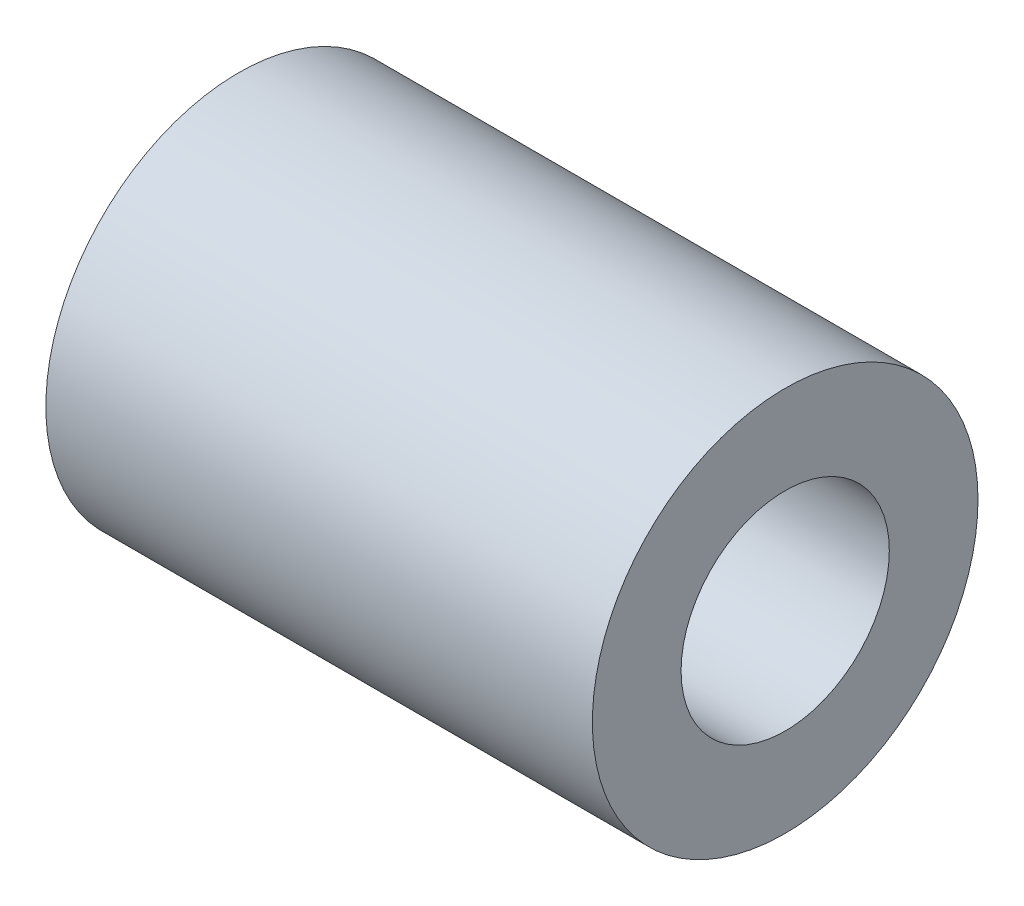
from build123d import *

# Parameters (mm, degrees)
ESQUISSE1_R        = 6.35
ESQUISSE1_R_2      = 3.429
BOSS_EXTRU_1_DEPTH = 18


with BuildPart() as part:
    # Esquisse1 → Boss.-Extru.1 (new body)
    with BuildSketch(Plane(origin=(0, 0, 0), x_dir=(0, 0, -1), z_dir=(1, 0, 0))):
        Circle(ESQUISSE1_R)
        Circle(ESQUISSE1_R_2, mode=Mode.SUBTRACT)
    extrude(amount=-BOSS_EXTRU_1_DEPTH)


solid = part.part
